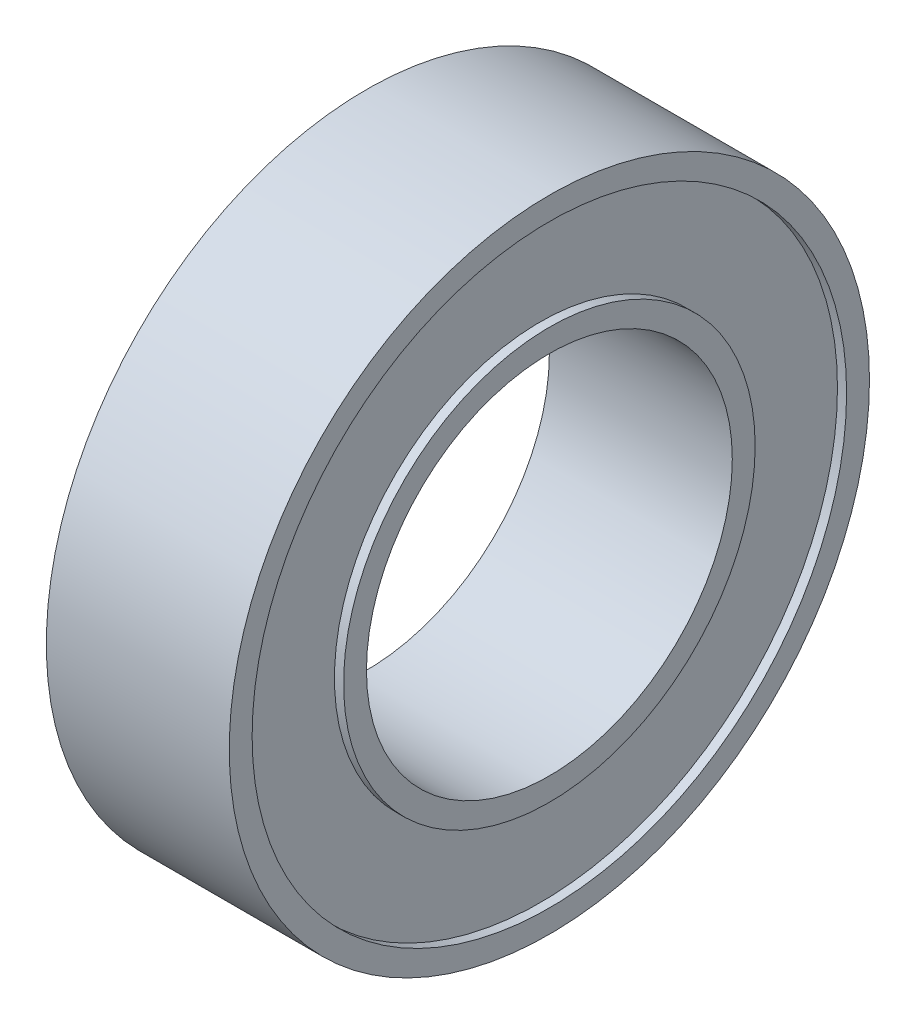
from build123d import *

# Parameters (mm, degrees)
SKETCH_1_R          = 7
SKETCH_1_R_2        = 4
EXTRUDE_1_DEPTH     = 4
SKETCH_2_R          = 6.5
SKETCH_2_R_2        = 4.5
CUT_EXTRUDE_1_DEPTH = 0.2
SKETCH_3_R          = 6.5
SKETCH_3_R_2        = 4.5
CUT_EXTRUDE_2_DEPTH = 0.2


with BuildPart() as part:
    # 草图1 → 凸台-拉伸1 (new body)
    with BuildSketch(Plane(origin=(0, 0, 0), x_dir=(0, 0, -1), z_dir=(1, 0, 0))):
        Circle(SKETCH_1_R)
        Circle(SKETCH_1_R_2, mode=Mode.SUBTRACT)
    extrude(amount=EXTRUDE_1_DEPTH)

    # 草图2 → 切除-拉伸1 (cut)
    with BuildSketch(Plane(origin=(4, 0, 0), x_dir=(0, 0, -1), z_dir=(1, 0, 0))):
        Circle(SKETCH_2_R)
        Circle(SKETCH_2_R_2, mode=Mode.SUBTRACT)
    extrude(amount=-CUT_EXTRUDE_1_DEPTH, mode=Mode.SUBTRACT)

    # 草图3 → 切除-拉伸2 (cut)
    with BuildSketch(Plane.ZY):
        Circle(SKETCH_3_R)
        Circle(SKETCH_3_R_2, mode=Mode.SUBTRACT)
    extrude(amount=-CUT_EXTRUDE_2_DEPTH, mode=Mode.SUBTRACT)


solid = part.part
